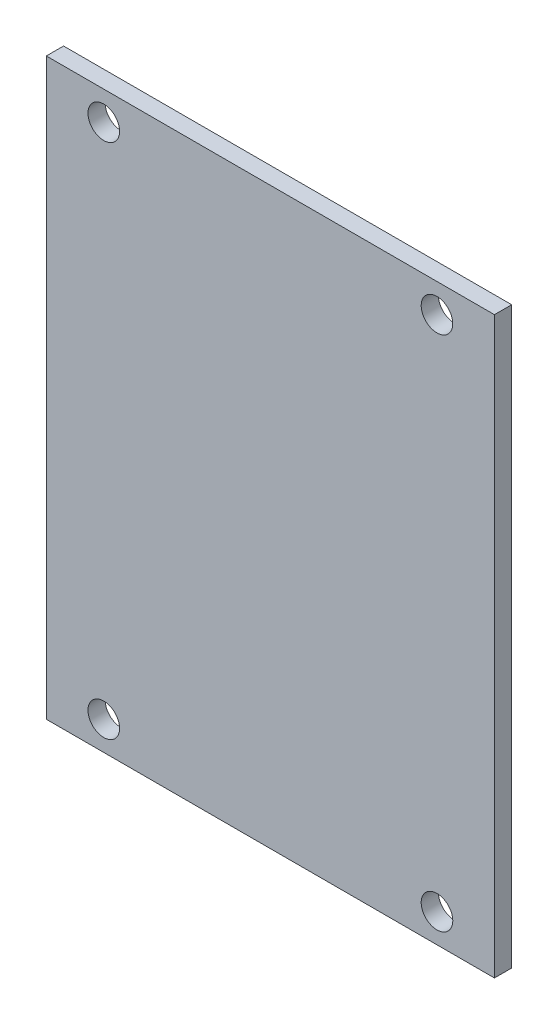
from build123d import *

# Parameters (mm, degrees)
SKETCH_1_W          = 78
SKETCH_1_H          = 100
EXTRUDE_1_DEPTH     = 3
SKETCH_3_R          = 2.75
CUT_EXTRUDE_1_DEPTH = 10


with BuildPart() as part:
    # 草图1 → 凸台-拉伸1 (new body)
    with BuildSketch(Plane.XY):
        with Locations((39, 50)):
            Rectangle(SKETCH_1_W, SKETCH_1_H)
    extrude(amount=EXTRUDE_1_DEPTH)

    # 草图3 → 切除-拉伸1 (cut)
    with BuildSketch(Plane.XY.offset(3)):
        with Locations((10, 95)):
            Circle(SKETCH_3_R)
        with Locations((10, 5)):
            Circle(SKETCH_3_R)
        with Locations((68, 5)):
            Circle(SKETCH_3_R)
        with Locations((68, 95)):
            Circle(SKETCH_3_R)
    extrude(amount=-CUT_EXTRUDE_1_DEPTH, mode=Mode.SUBTRACT)


solid = part.part
